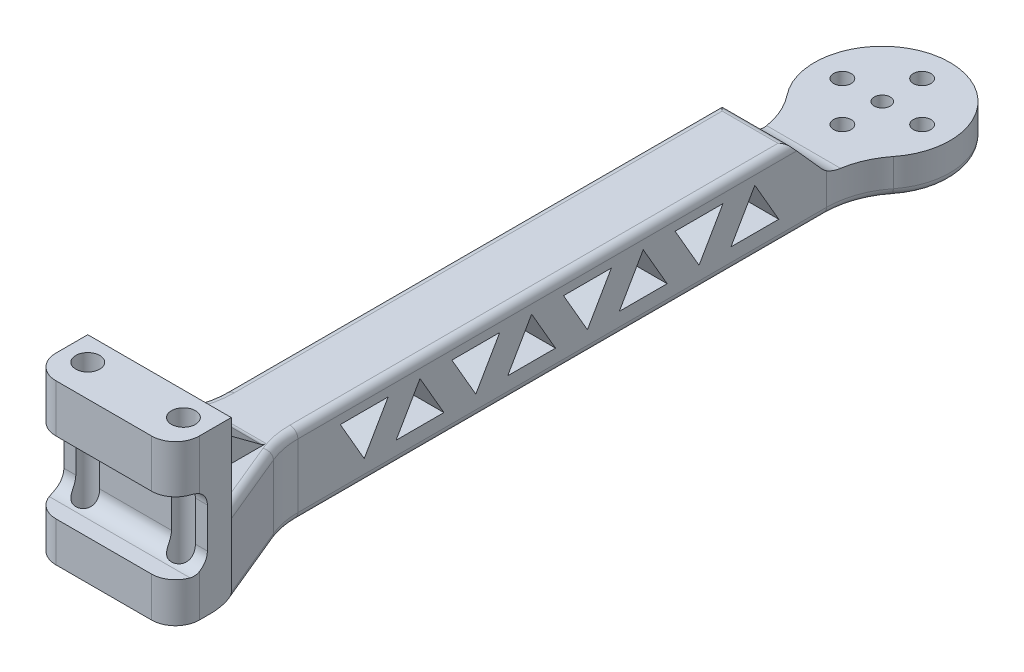
from build123d import *

# Parameters (mm, degrees)
BOSS_EXTRUDE1_DEPTH     = 10
CUT_EXTRUDE1_DEPTH      = 19.370764901
CUT_EXTRUDE1_DEPTH_BACK = 1
SKETCH3_R               = 1
SKETCH3_R_2             = 1.1
CUT_EXTRUDE2_DEPTH      = 6.5
CUT_EXTRUDE2_DEPTH_BACK = 5.5000001
BOSS_EXTRUDE2_DEPTH     = 10
SKETCH5_R               = 1.5
CUT_EXTRUDE3_DEPTH      = 21.0000001
CUT_EXTRUDE4_DEPTH      = 19
CUT_EXTRUDE5_DEPTH      = 14.5000001
BOSS_EXTRUDE3_START     = -5
BOSS_EXTRUDE3_DEPTH     = 8
FILLET2_R               = 1
FILLET3_R               = 1
SKETCH11_R              = 1.25
CUT_EXTRUDE12_DEPTH     = 4


with BuildPart() as part:
    # Sketch1 → Boss-Extrude1 (new body)
    with BuildSketch(Plane(origin=(0, 0, 0), x_dir=(1, 0, 0), z_dir=(0, 1, 0))):
        with BuildLine():
            Line((3.370764901, 0), (15.370764901, 0))
            ThreePointArc((15.370764901, 0), (17.492085245, 0.878679656), (18.370764901, 3))
            Line((18.370764901, 3), (18.370764901, 7))
            Line((18.370764901, 7), (14.631969576, 16.026250381))
            ThreePointArc((14.631969576, 16.026250381), (14.062912097, 17.902181484), (13.870764901, 19.853084704))
            Line((13.870764901, 19.853084704), (13.870764901, 86.161977258))
            ThreePointArc((13.870764901, 86.161977258), (14.426762085, 89.449957004), (16.032927063, 92.372315254))
            ThreePointArc((16.032927063, 92.372315254), (9.370764901, 106.151102551), (2.708602739, 92.372315254))
            ThreePointArc((2.708602739, 92.372315254), (4.314767717, 89.449957004), (4.870764901, 86.161977258))
            Line((4.870764901, 86.161977258), (4.870764901, 19.853084704))
            ThreePointArc((4.870764901, 19.853084704), (4.678617705, 17.902181484), (4.109560226, 16.026250381))
            Line((4.109560226, 16.026250381), (0.370764901, 7))
            Line((0.370764901, 7), (0.370764901, 3))
            ThreePointArc((0.370764901, 3), (1.249444558, 0.878679656), (3.370764901, 0))
        make_face()
    extrude(amount=BOSS_EXTRUDE1_DEPTH)

    # Sketch2 → Cut-Extrude1 (cut, two sides)
    with BuildSketch(Plane(origin=(0, 0, 0), x_dir=(0, 0, -1), z_dir=(1, 0, 0))) as cut_extrude1_sk:
        with BuildLine():
            Line((79.695640218, 12.044389059), (85.546639403, 5.500402589))
            ThreePointArc((85.546639403, 5.500402589), (86.558076021, 4.761497468), (87.783067402, 4.5))
            Line((87.783067402, 4.5), (106.151102551, 4.5))
            Line((106.151102551, 4.5), (106.151102551, 14.134482691))
            Line((106.151102551, 14.134482691), (79.695640218, 14.134482691))
            Line((79.695640218, 14.134482691), (79.695640218, 12.044389059))
        make_face()
    extrude(amount=CUT_EXTRUDE1_DEPTH, mode=Mode.SUBTRACT)
    extrude(cut_extrude1_sk.sketch, amount=-CUT_EXTRUDE1_DEPTH_BACK, mode=Mode.SUBTRACT)

    # Sketch3 → Cut-Extrude2 (cut, two sides)
    with BuildSketch(Plane(origin=(0, 4.5, 0), x_dir=(1, 0, 0), z_dir=(0, 1, 0))) as cut_extrude2_sk:
        with Locations((9.370764901, 97.651102551)):
            Circle(SKETCH3_R)
        with Locations((9.370764901, 102.651102551)):
            Circle(SKETCH3_R_2)
        with Locations((14.370764901, 97.651102551)):
            Circle(SKETCH3_R_2)
        with Locations((9.370764901, 92.651102551)):
            Circle(SKETCH3_R_2)
        with Locations((4.370764901, 97.651102551)):
            Circle(SKETCH3_R_2)
    extrude(amount=CUT_EXTRUDE2_DEPTH, mode=Mode.SUBTRACT)
    extrude(cut_extrude2_sk.sketch, amount=-CUT_EXTRUDE2_DEPTH_BACK, mode=Mode.SUBTRACT)

    # Sketch4 → Boss-Extrude2 (add)
    with BuildSketch(Plane(origin=(0, 10, 0), x_dir=(1, 0, 0), z_dir=(0, 1, 0))):
        with BuildLine():
            Line((18.370764901, 7), (0.370764901, 7))
            Line((0.370764901, 7), (0.370764901, 3))
            ThreePointArc((0.370764901, 3), (1.249444558, 0.878679656), (3.370764901, 0))
            Line((3.370764901, 0), (15.370764901, 0))
            ThreePointArc((15.370764901, 0), (17.492085245, 0.878679656), (18.370764901, 3))
            Line((18.370764901, 3), (18.370764901, 7))
        make_face()
    extrude(amount=BOSS_EXTRUDE2_DEPTH)

    # Sketch5 → Cut-Extrude3 (cut, through all)
    with BuildSketch(Plane(origin=(0, 20, 0), x_dir=(1, 0, 0), z_dir=(0, 1, 0))):
        with Locations((3.370764901, 4)):
            Circle(SKETCH5_R)
        with Locations((15.370764901, 4)):
            Circle(SKETCH5_R)
    extrude(amount=-CUT_EXTRUDE3_DEPTH, mode=Mode.SUBTRACT)

    # Sketch6 → Cut-Extrude4 (cut, through all)
    with BuildSketch(Plane(origin=(18.370764901, 0, 0), x_dir=(0, 0, -1), z_dir=(1, 0, 0))):
        with BuildLine():
            Line((0, 14), (2, 14))
            ThreePointArc((2, 14), (3.414213562, 13.414213562), (4, 12))
            Line((4, 12), (4, 7))
            ThreePointArc((4, 7), (3.414213562, 5.585786438), (2, 5))
            Line((2, 5), (0, 5))
            Line((0, 5), (0, 14))
        make_face()
    extrude(amount=-CUT_EXTRUDE4_DEPTH, mode=Mode.SUBTRACT)

    # Sketch7 → Cut-Extrude5 (cut, through all)
    with BuildSketch(Plane.ZY.offset(-4.870764901)):
        Polygon((-77.173535, 7.896152423), (-80.173535, 2.7), (-74.173535, 2.7), align=None)
        Polygon((-73.173535, 7.9), (-70.173535, 2.703847577), (-67.173535, 7.9), align=None)
        Polygon((-63.173535, 7.896152423), (-66.173535, 2.7), (-60.173535, 2.7), align=None)
        Polygon((-59.173535, 7.9), (-56.173535, 2.703847577), (-53.173535, 7.9), align=None)
        Polygon((-49.173535, 7.896152423), (-52.173535, 2.7), (-46.173535, 2.7), align=None)
        Polygon((-45.173535, 7.9), (-42.173535, 2.703847577), (-39.173535, 7.9), align=None)
        Polygon((-35.173535, 7.896152423), (-38.173535, 2.7), (-32.173535, 2.7), align=None)
        Polygon((-31.173535, 7.9), (-28.173535, 2.703847577), (-25.173535, 7.9), align=None)
    extrude(amount=-CUT_EXTRUDE5_DEPTH, mode=Mode.SUBTRACT)

    # Sketch9 → Boss-Extrude3 (add)
    with BuildSketch(Plane.ZY.offset(-0.370764901).offset(BOSS_EXTRUDE3_START)):
        Polygon((-7, 16.671459489), (-7, 10), (-16.026250381, 10), align=None)
    extrude(amount=-BOSS_EXTRUDE3_DEPTH)

    # Fillet2
    fillet2_edges = [part.edges().sort_by_distance(p)[0] for p in [
        (16.501367239, 0, -11.51312519),
        (2.240162564, 0, -11.51312519),
        (4.678617705, 0, -17.902181484),
        (4.870764901, 0, -53.007530981),
        (4.314767717, 0, -89.449957004),
        (9.370764901, 0, -106.151102551),
        (14.426762085, 0, -89.449957004),
        (13.870764901, 0, -53.007530981),
        (14.062912097, 0, -17.902181484),
        (4.678617705, 10, -17.902181484),
        (2.240162564, 10, -11.51312519),
        (4.870764901, 10, -50.688309852),
        (9.370764901, 10, -81.523535),
        (14.062912097, 10, -17.902181484),
        (16.501367239, 10, -11.51312519),
        (13.870764901, 10, -50.688309852),
    ]]
    fillet(fillet2_edges, radius=FILLET2_R)

    # Fillet3
    fillet3_edges = [part.edges().sort_by_distance(p)[0] for p in [
        (9.370764901, 10, -16.026250381),
        (9.370764901, 16.671459489, -7),
    ]]
    fillet(fillet3_edges, radius=FILLET3_R)

    # Sketch11 → Cut-Extrude12 (cut)
    with BuildSketch(Plane.XZ):
        with Locations((9.370764901, -62.644330493)):
            Circle(SKETCH11_R)
    extrude(amount=-CUT_EXTRUDE12_DEPTH, mode=Mode.SUBTRACT)


solid = part.part
